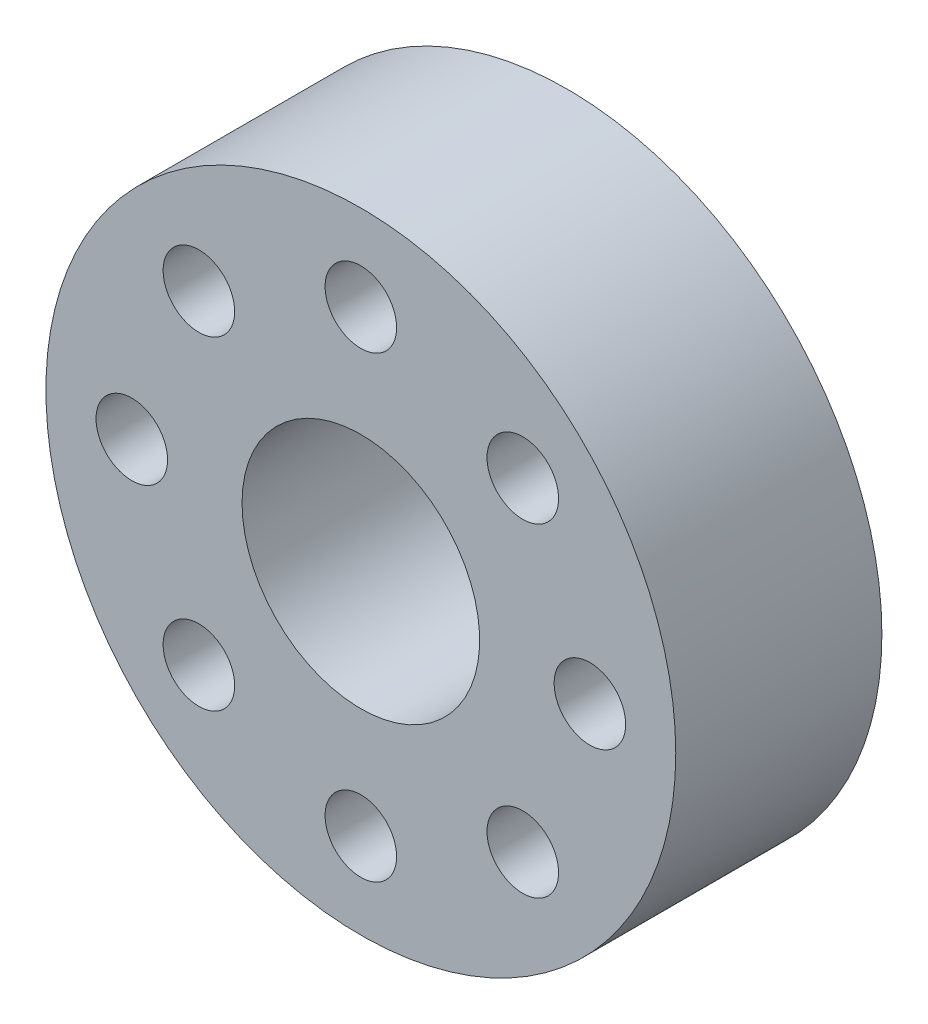
from build123d import *

# Parameters (mm, degrees)
SKETCH2_R           = 11
BOSS_EXTRUDE1_DEPTH = 7.2
SKETCH3_R           = 4.15
SKETCH3_R_2         = 1.25
CUT_EXTRUDE1_DEPTH  = 8.2


with BuildPart() as part:
    # Sketch2 → Boss-Extrude1 (new body)
    with BuildSketch(Plane.XY):
        Circle(SKETCH2_R)
    extrude(amount=BOSS_EXTRUDE1_DEPTH)

    # Sketch3 → Cut-Extrude1 (cut, through all)
    with BuildSketch(Plane(origin=(0, 0, 0), x_dir=(-1, 0, 0), z_dir=(0, 0, -1))):
        Circle(SKETCH3_R)
        with Locations((8, 0)):
            Circle(SKETCH3_R_2)
        with Locations((5.656854249, -5.656854249)):
            Circle(SKETCH3_R_2)
        with Locations((0, -8)):
            Circle(SKETCH3_R_2)
        with Locations((-5.656854249, -5.656854249)):
            Circle(SKETCH3_R_2)
        with Locations((-8, 0)):
            Circle(SKETCH3_R_2)
        with Locations((-5.656854249, 5.656854249)):
            Circle(SKETCH3_R_2)
        with Locations((0, 8)):
            Circle(SKETCH3_R_2)
        with Locations((5.656854249, 5.656854249)):
            Circle(SKETCH3_R_2)
    extrude(amount=-CUT_EXTRUDE1_DEPTH, mode=Mode.SUBTRACT)


solid = part.part
